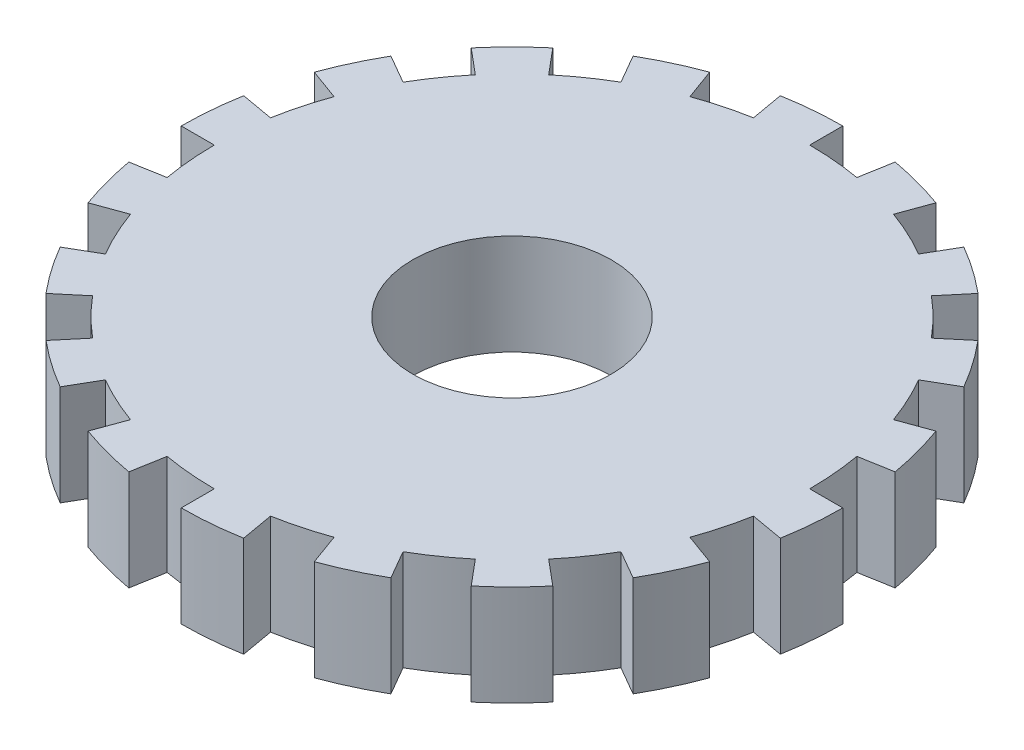
from build123d import *

# Parameters (mm, degrees)
SKETCH1_R           = 31.75
SKETCH1_R_2         = 9.525
BOSS_EXTRUDE1_DEPTH = 9.652
CUT_EXTRUDE1_DEPTH  = 10.652


with BuildPart() as part:
    # Sketch1 → Boss-Extrude1 (new body)
    with BuildSketch(Plane(origin=(0, 0, 0), x_dir=(1, 0, 0), z_dir=(0, 1, 0))):
        Circle(SKETCH1_R)
        Circle(SKETCH1_R_2, mode=Mode.SUBTRACT)
    extrude(amount=BOSS_EXTRUDE1_DEPTH)

    # Sketch2 → Cut-Extrude1 (cut, through all)
    with BuildSketch(Plane(origin=(0, 9.652, 0), x_dir=(1, 0, 0), z_dir=(0, 1, 0))):
        with BuildLine():
            Line((28.575, 0), (43.782696044, 0))
            Line((43.782696044, 0), (43.782696044, 7.720070601))
            Line((43.782696044, 7.720070601), (28.140881542, 4.961996677))
            ThreePointArc((28.140881542, 4.961996677), (28.466263498, 2.490475349), (28.575, 0))
        make_face()
        with BuildLine():
            Line((28.140881542, -4.961996677), (43.782696044, -7.720070601))
            Line((43.782696044, -7.720070601), (41.14227639, -14.974563976))
            Line((41.14227639, -14.974563976), (26.851716639, -9.773225596))
            ThreePointArc((26.851716639, -9.773225596), (27.601330486, -7.395754214), (28.140881542, -4.961996677))
        make_face()
        with BuildLine():
            Line((24.746675913, -14.2875), (38.501856737, -22.229057351))
            Line((38.501856737, -22.229057351), (33.539491009, -28.142974536))
            Line((33.539491009, -28.142974536), (21.889719962, -18.367655947))
            ThreePointArc((21.889719962, -18.367655947), (23.407269666, -16.389946669), (24.746675913, -14.2875))
        make_face()
        with BuildLine():
            Line((18.367655947, -21.889719962), (28.577125281, -34.05689172))
            Line((28.577125281, -34.05689172), (21.891348022, -37.91692702))
            Line((21.891348022, -37.91692702), (14.2875, -24.746675913))
            ThreePointArc((14.2875, -24.746675913), (16.389946669, -23.407269666), (18.367655947, -21.889719962))
        make_face()
        with BuildLine():
            Line((9.773225596, -26.851716639), (15.205570763, -41.77696232))
            Line((15.205570763, -41.77696232), (7.602785381, -43.117538512))
            Line((7.602785381, -43.117538512), (4.961996677, -28.140881542))
            ThreePointArc((4.961996677, -28.140881542), (7.395754214, -27.601330486), (9.773225596, -26.851716639))
        make_face()
        with BuildLine():
            Line((0, -28.575), (0, -44.458114703))
            Line((0, -44.458114703), (-7.602785381, -43.117538512))
            Line((-7.602785381, -43.117538512), (-4.961996677, -28.140881542))
            ThreePointArc((-4.961996677, -28.140881542), (-2.490475349, -28.466263498), (0, -28.575))
        make_face()
        with BuildLine():
            Line((-9.773225596, -26.851716639), (-15.205570763, -41.77696232))
            Line((-15.205570763, -41.77696232), (-21.891348022, -37.91692702))
            Line((-21.891348022, -37.91692702), (-14.2875, -24.746675913))
            ThreePointArc((-14.2875, -24.746675913), (-12.076316829, -25.897745015), (-9.773225596, -26.851716639))
        make_face()
        with BuildLine():
            Line((-18.367655947, -21.889719962), (-28.577125281, -34.05689172))
            Line((-28.577125281, -34.05689172), (-33.539491009, -28.142974536))
            Line((-33.539491009, -28.142974536), (-21.889719962, -18.367655947))
            ThreePointArc((-21.889719962, -18.367655947), (-20.205576272, -20.205576272), (-18.367655947, -21.889719962))
        make_face()
        with BuildLine():
            Line((-24.746675913, -14.2875), (-38.501856737, -22.229057351))
            Line((-38.501856737, -22.229057351), (-41.14227639, -14.974563976))
            Line((-41.14227639, -14.974563976), (-26.851716639, -9.773225596))
            ThreePointArc((-26.851716639, -9.773225596), (-25.897745015, -12.076316829), (-24.746675913, -14.2875))
        make_face()
        with BuildLine():
            Line((-28.140881542, -4.961996677), (-43.782696044, -7.720070601))
            Line((-43.782696044, -7.720070601), (-43.782696044, 0))
            Line((-43.782696044, 0), (-28.575, 0))
            ThreePointArc((-28.575, 0), (-28.466263498, -2.490475349), (-28.140881542, -4.961996677))
        make_face()
        with BuildLine():
            Line((-28.140881542, 4.961996677), (-43.782696044, 7.720070601))
            Line((-43.782696044, 7.720070601), (-41.14227639, 14.974563976))
            Line((-41.14227639, 14.974563976), (-26.851716639, 9.773225596))
            ThreePointArc((-26.851716639, 9.773225596), (-27.601330486, 7.395754214), (-28.140881542, 4.961996677))
        make_face()
        with BuildLine():
            Line((-24.746675913, 14.2875), (-38.501856737, 22.229057351))
            Line((-38.501856737, 22.229057351), (-33.539491009, 28.142974536))
            Line((-33.539491009, 28.142974536), (-21.889719962, 18.367655947))
            ThreePointArc((-21.889719962, 18.367655947), (-23.407269666, 16.389946669), (-24.746675913, 14.2875))
        make_face()
        with BuildLine():
            Line((-18.367655947, 21.889719962), (-28.577125281, 34.05689172))
            Line((-28.577125281, 34.05689172), (-21.891348022, 37.91692702))
            Line((-21.891348022, 37.91692702), (-14.2875, 24.746675913))
            ThreePointArc((-14.2875, 24.746675913), (-16.389946669, 23.407269666), (-18.367655947, 21.889719962))
        make_face()
        with BuildLine():
            Line((-9.773225596, 26.851716639), (-15.205570763, 41.77696232))
            Line((-15.205570763, 41.77696232), (-7.602785381, 43.117538512))
            Line((-7.602785381, 43.117538512), (-4.961996677, 28.140881542))
            ThreePointArc((-4.961996677, 28.140881542), (-7.395754214, 27.601330486), (-9.773225596, 26.851716639))
        make_face()
        with BuildLine():
            Line((0, 28.575), (0, 44.458114703))
            Line((0, 44.458114703), (7.602785381, 43.117538512))
            Line((7.602785381, 43.117538512), (4.961996677, 28.140881542))
            ThreePointArc((4.961996677, 28.140881542), (2.490475349, 28.466263498), (0, 28.575))
        make_face()
        with BuildLine():
            Line((9.773225596, 26.851716639), (15.205570763, 41.77696232))
            Line((15.205570763, 41.77696232), (21.891348022, 37.91692702))
            Line((21.891348022, 37.91692702), (14.2875, 24.746675913))
            ThreePointArc((14.2875, 24.746675913), (12.076316829, 25.897745015), (9.773225596, 26.851716639))
        make_face()
        with BuildLine():
            Line((18.367655947, 21.889719962), (28.577125281, 34.05689172))
            Line((28.577125281, 34.05689172), (33.539491009, 28.142974536))
            Line((33.539491009, 28.142974536), (21.889719962, 18.367655947))
            ThreePointArc((21.889719962, 18.367655947), (20.205576272, 20.205576272), (18.367655947, 21.889719962))
        make_face()
        with BuildLine():
            Line((24.746675913, 14.2875), (38.501856737, 22.229057351))
            Line((38.501856737, 22.229057351), (41.14227639, 14.974563976))
            Line((41.14227639, 14.974563976), (26.851716639, 9.773225596))
            ThreePointArc((26.851716639, 9.773225596), (25.897745015, 12.076316829), (24.746675913, 14.2875))
        make_face()
    extrude(amount=-CUT_EXTRUDE1_DEPTH, mode=Mode.SUBTRACT)


solid = part.part
